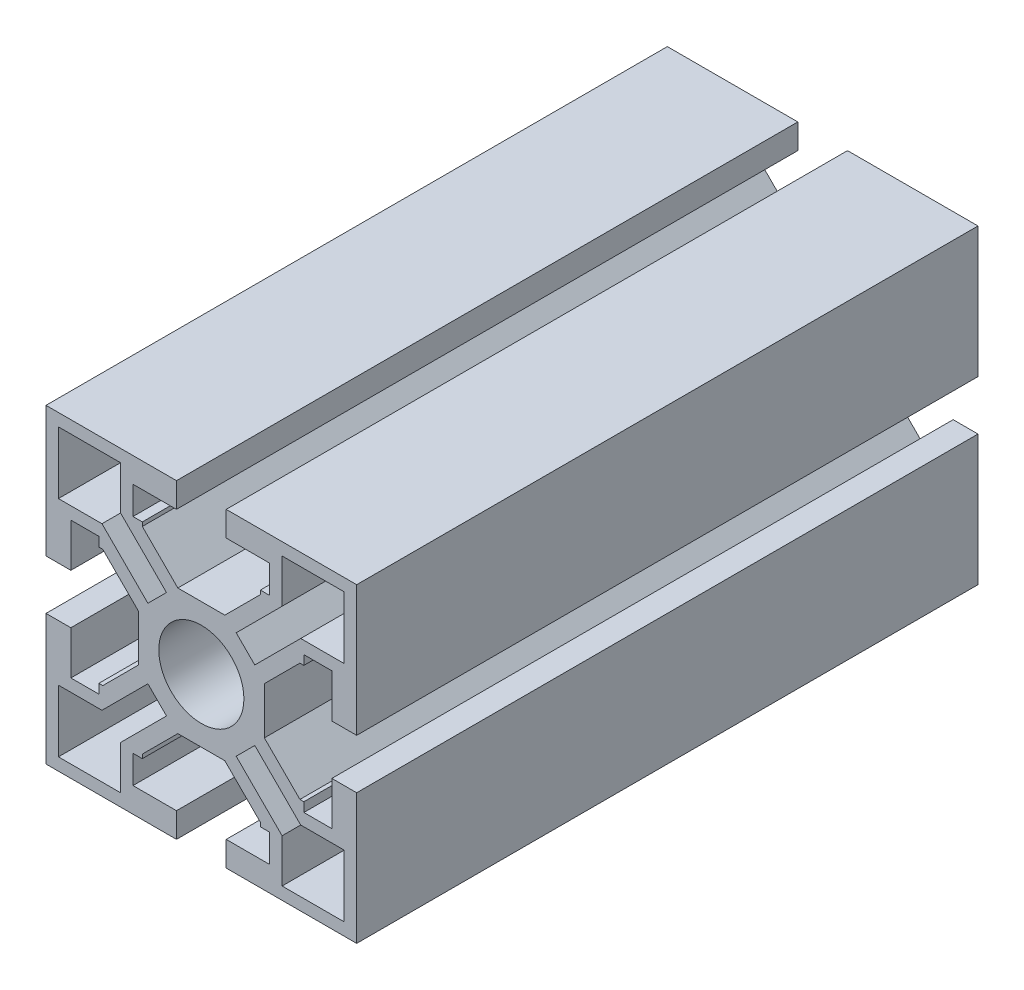
from build123d import *

# Parameters (mm, degrees)
SKETCH_A01_1_R     = 6.85
SKETCH_A01_1_W     = 10
SKETCH_A01_1_H     = 10
EXTRUDE1_DEPTH     = 100
CUT_EXTRUDE1_DEPTH = 101
CIRPATTERN1_COUNT  = 4


with BuildPart() as part:
    # Sketch A01-1 → Extrude1 (new body)
    with BuildSketch(Plane.XY):
        Polygon((-16.5, -11), (-16.5, -9.5), (-15.863961, -9.5), (-10.14602885, -3.78206785), (-10.14602885, 3.78206785), (-15.863961, 9.5), (-16.5, 9.5), (-16.5, 11), (-21, 11), (-21, 4), (-25, 4), (-25, 25), (-4, 25), (-4, 21), (-11, 21), (-11, 16.5), (-9.5, 16.5), (-9.5, 15.863961), (-3.78206785, 10.14602885), (3.78206785, 10.14602885), (9.5, 15.863961), (9.5, 16.5), (11, 16.5), (11, 21), (4, 21), (4, 25), (25, 25), (25, 4), (21, 4), (21, 11), (16.5, 11), (16.5, 9.5), (15.863961, 9.5), (10.14602885, 3.78206785), (10.14602885, -3.78206785), (15.863961, -9.5), (16.5, -9.5), (16.5, -11), (21, -11), (21, -4), (25, -4), (25, -25), (4, -25), (4, -21), (11, -21), (11, -16.5), (9.5, -16.5), (9.5, -15.863961), (3.78206785, -10.14602885), (-3.78206785, -10.14602885), (-9.5, -15.863961), (-9.5, -16.5), (-11, -16.5), (-11, -21), (-4, -21), (-4, -25), (-25, -25), (-25, -4), (-21, -4), (-21, -11), align=None)
        Circle(SKETCH_A01_1_R, mode=Mode.SUBTRACT)
        with Locations((-18, -18)):
            Rectangle(SKETCH_A01_1_W, SKETCH_A01_1_H, mode=Mode.SUBTRACT)
        with Locations((18, -18)):
            Rectangle(SKETCH_A01_1_W, SKETCH_A01_1_H, mode=Mode.SUBTRACT)
        with Locations((-18, 18)):
            Rectangle(SKETCH_A01_1_W, SKETCH_A01_1_H, mode=Mode.SUBTRACT)
        with Locations((18, 18)):
            Rectangle(SKETCH_A01_1_W, SKETCH_A01_1_H, mode=Mode.SUBTRACT)
    extrude(amount=-EXTRUDE1_DEPTH)

    # Sketch1 → Cut-Extrude1 (cut, through all)
    with BuildSketch(Plane.XY):
        Polygon((-15.993494496, 13), (-8.602622103, 5.609127607), (-5.609127607, 8.602622103), (-13, 15.993494496), align=None)
    cut_extrude1 = extrude(amount=-CUT_EXTRUDE1_DEPTH, mode=Mode.SUBTRACT)

    # CirPattern1: Cut-Extrude1 ×4 about axis
    cirpattern1_axis = Axis((0, 0, 0), (0, 0, 1))
    for i in range(1, CIRPATTERN1_COUNT):
        add(cut_extrude1.rotate(cirpattern1_axis, i * 360 / CIRPATTERN1_COUNT), mode=Mode.SUBTRACT)


solid = part.part
